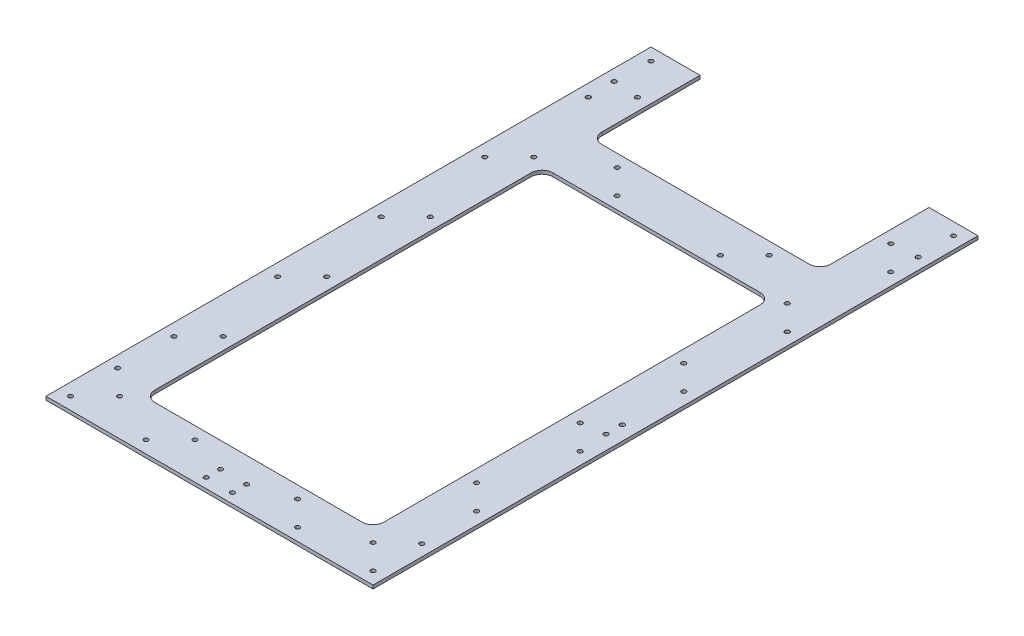
from build123d import *

# Parameters (mm, degrees)
SKETCH1_W           = 300
SKETCH1_H           = 600
BOSS_EXTRUDE1_DEPTH = 3.175
CUT_EXTRUDE1_DEPTH  = 10
SKETCH4_R           = 2.05
CUT_EXTRUDE2_DEPTH  = 51
SKETCH5_R           = 2.1
CUT_EXTRUDE3_DEPTH  = 67
SKETCH7_R           = 2.05
CUT_EXTRUDE4_DEPTH  = 10
SKETCH8_R           = 2.1
CUT_EXTRUDE5_DEPTH  = 10


with BuildPart() as part:
    # Sketch1 → Boss-Extrude1 (new body)
    with BuildSketch(Plane(origin=(0, 0, 0), x_dir=(1, 0, 0), z_dir=(0, 1, 0))):
        Rectangle(SKETCH1_W, SKETCH1_H)
    extrude(amount=BOSS_EXTRUDE1_DEPTH)

    # Sketch3 → Cut-Extrude1 (cut)
    with BuildSketch(Plane(origin=(0, 3.175, 0), x_dir=(1, 0, 0), z_dir=(0, 1, 0))):
        with BuildLine():
            Line((-95, -255), (95, -255))
            ThreePointArc((95, -255), (102.071067812, -252.071067812), (105, -245))
            Line((105, -245), (105, 100))
            ThreePointArc((105, 100), (102.071067812, 107.071067812), (95, 110))
            Line((95, 110), (-95, 110))
            ThreePointArc((-95, 110), (-102.071067812, 107.071067812), (-105, 100))
            Line((-105, 100), (-105, -245))
            ThreePointArc((-105, -245), (-102.071067812, -252.071067812), (-95, -255))
        make_face()
        with BuildLine():
            Line((105, 255), (105, 165))
            ThreePointArc((105, 165), (102.071067812, 157.928932188), (95, 155))
            Line((95, 155), (-95, 155))
            ThreePointArc((-95, 155), (-102.071067992, 157.928932157), (-105.000000511, 165))
            Line((-105.000000511, 165), (-105.000005107, 255))
            Line((-105.000005107, 255), (-150, 255))
            Line((-150, 255), (-150, 300))
            Line((-150, 300), (150, 300))
            Line((150, 300), (150, 255))
            Line((150, 255), (105, 255))
        make_face()
    extrude(amount=-CUT_EXTRUDE1_DEPTH, mode=Mode.SUBTRACT)

    # Sketch4 → Cut-Extrude2 (cut)
    with BuildSketch(Plane(origin=(0, 3.175, 0), x_dir=(1, 0, 0), z_dir=(0, 1, 0))):
        with Locations((12, -291)):
            Circle(SKETCH4_R)
        with Locations((-12, -291)):
            Circle(SKETCH4_R)
        with Locations((-12, -278)):
            Circle(SKETCH4_R)
        with Locations((12, -278)):
            Circle(SKETCH4_R)
    extrude(amount=-CUT_EXTRUDE2_DEPTH, mode=Mode.SUBTRACT)

    # Sketch5 → Cut-Extrude3 (cut)
    with BuildSketch(Plane(origin=(0, 3.175, 0), x_dir=(1, 0, 0), z_dir=(0, 1, 0))):
        with Locations((137, -73.264775169)):
            Circle(SKETCH5_R)
        with Locations((137, -58.264775169)):
            Circle(SKETCH5_R)
    extrude(amount=-CUT_EXTRUDE3_DEPTH, mode=Mode.SUBTRACT)

    # Sketch7 → Cut-Extrude4 (cut)
    with BuildSketch(Plane(origin=(0, 3.175, 0), x_dir=(1, 0, 0), z_dir=(0, 1, 0))):
        with Locations((138.75, -288.75)):
            Circle(SKETCH7_R)
        with Locations((116.25, -266.25)):
            Circle(SKETCH7_R)
        with Locations((47.023601507, -266.25)):
            Circle(SKETCH7_R)
        with Locations((69.523601507, -288.75)):
            Circle(SKETCH7_R)
        with Locations((116.25, -171.25)):
            Circle(SKETCH7_R)
        with Locations((138.75, -193.75)):
            Circle(SKETCH7_R)
        with Locations((116.25, -76.25)):
            Circle(SKETCH7_R)
        with Locations((138.75, -98.75)):
            Circle(SKETCH7_R)
        with Locations((116.25, 18.75)):
            Circle(SKETCH7_R)
        with Locations((138.75, -3.75)):
            Circle(SKETCH7_R)
        with Locations((116.25, 113.75)):
            Circle(SKETCH7_R)
        with Locations((138.75, 91.25)):
            Circle(SKETCH7_R)
        with Locations((116.25, 208.75)):
            Circle(SKETCH7_R)
        with Locations((138.75, 186.25)):
            Circle(SKETCH7_R)
        with Locations((47.357849803, 121.25)):
            Circle(SKETCH7_R)
        with Locations((69.635017605, 143.75)):
            Circle(SKETCH7_R)
        with Locations((-47.357849803, 121.25)):
            Circle(SKETCH7_R)
        with Locations((-69.635017605, 143.75)):
            Circle(SKETCH7_R)
        with Locations((-116.25, 208.75)):
            Circle(SKETCH7_R)
        with Locations((-138.75, 186.25)):
            Circle(SKETCH7_R)
        with Locations((-138.75, 91.25)):
            Circle(SKETCH7_R)
        with Locations((-116.25, 18.75)):
            Circle(SKETCH7_R)
        with Locations((-116.25, 113.75)):
            Circle(SKETCH7_R)
        with Locations((-116.25, -76.25)):
            Circle(SKETCH7_R)
        with Locations((-138.75, -3.75)):
            Circle(SKETCH7_R)
        with Locations((-138.75, -98.75)):
            Circle(SKETCH7_R)
        with Locations((-116.25, -171.25)):
            Circle(SKETCH7_R)
        with Locations((-138.75, -193.75)):
            Circle(SKETCH7_R)
        with Locations((-116.25, -266.25)):
            Circle(SKETCH7_R)
        with Locations((-138.75, -288.75)):
            Circle(SKETCH7_R)
        with Locations((-47.023601507, -266.25)):
            Circle(SKETCH7_R)
        with Locations((-69.523601507, -288.75)):
            Circle(SKETCH7_R)
        with Locations((-138.75, 243.75)):
            Circle(SKETCH7_R)
        with Locations((138.75, 243.75)):
            Circle(SKETCH7_R)
    extrude(amount=-CUT_EXTRUDE4_DEPTH, mode=Mode.SUBTRACT)

    # Sketch8 → Cut-Extrude5 (cut)
    with BuildSketch(Plane(origin=(0, 3.175, 0), x_dir=(1, 0, 0), z_dir=(0, 1, 0))):
        with Locations((139.5, 210.665995932)):
            Circle(SKETCH8_R)
        with Locations((139.5, -244.701867271)):
            Circle(SKETCH8_R)
    cut_extrude5 = extrude(amount=-CUT_EXTRUDE5_DEPTH, mode=Mode.SUBTRACT)

    # Mirror1: Cut-Extrude5 across plane
    add(cut_extrude5.mirror(Plane(origin=(0, 0, 0), x_dir=(0, 0, 1), z_dir=(1, 0, 0))), mode=Mode.SUBTRACT)


solid = part.part
